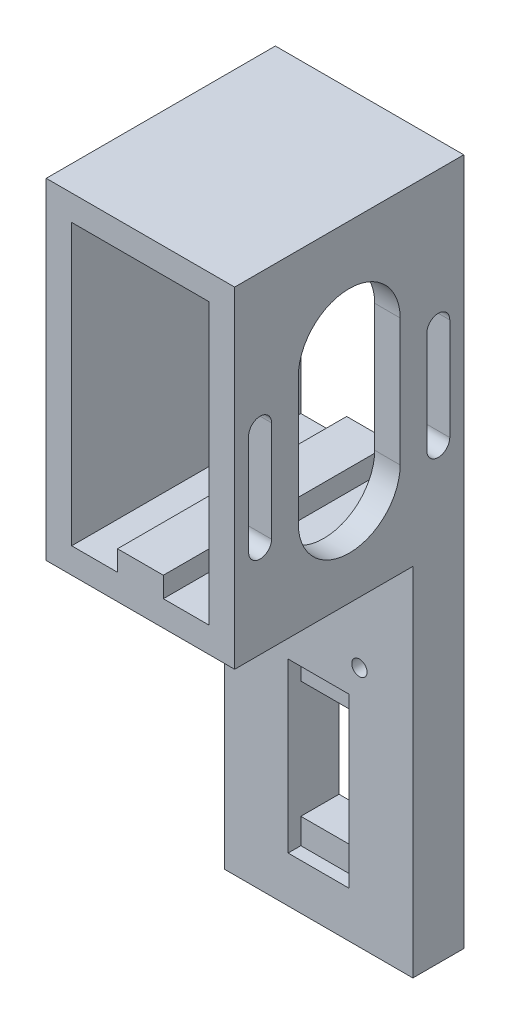
from build123d import *

# Parameters (mm, degrees)
BOSS_EXTRU_1_DEPTH      = 45
ENL_V_MAT_EXTRU_1_DEPTH = 5
ESQUISSE4_W             = 37
ESQUISSE4_H             = 45
BOSS_EXTRU_2_DEPTH      = 5
ESQUISSE5_W             = 37
ESQUISSE5_H             = 10
BOSS_EXTRU_3_DEPTH      = 70
ESQUISSE6_R             = 1
ENL_V_MAT_EXTRU_2_DEPTH = 10
CHANFREIN2_SIZE         = 1
ESQUISSE7_W             = 12
ESQUISSE7_H             = 23
ENL_V_MAT_EXTRU_3_DEPTH = 10
ESQUISSE8_W             = 12
ESQUISSE8_H             = 5
ENL_V_MAT_EXTRU_4_DEPTH = 2.5
ESQUISSE10_R            = 1.5
ENL_V_MAT_EXTRU_5_DEPTH = 10


with BuildPart() as part:
    # Esquisse1 → Boss.-Extru.1 (new body)
    with BuildSketch(Plane.XY):
        Polygon((-40.10574777, 31.587127795), (-35.10574777, 31.587127795), (-35.10574777, -23.412872205), (-26.10574777, -23.412872205), (-26.10574777, -19.412872205), (-17.10574777, -19.412872205), (-17.10574777, -23.412872205), (-8.10574777, -23.412872205), (-8.10574777, 31.587127795), (-3.10574777, 31.587127795), (-3.10574777, -28.412872205), (-40.10574777, -28.412872205), align=None)
    extrude(amount=BOSS_EXTRU_1_DEPTH)

    # Esquisse2 → Enlèv. mat.-Extru.1 (cut)
    with BuildSketch(Plane(origin=(-3.10574777, 0, 0), x_dir=(0, 0, -1), z_dir=(1, 0, 0))):
        with BuildLine():
            Line((-12.5, 15.087127795), (-12.5, -9.912872205))
            ThreePointArc((-12.5, -9.912872205), (-22.5, -19.912872205), (-32.5, -9.912872205))
            Line((-32.5, -9.912872205), (-32.5, 15.087127795))
            ThreePointArc((-32.5, 15.087127795), (-22.5, 25.087127795), (-12.5, 15.087127795))
        make_face()
        with BuildLine():
            Line((-37.75, 9.877519714), (-37.75, -9.912872205))
            ThreePointArc((-37.75, -9.912872205), (-40, -12.162872205), (-42.25, -9.912872205))
            Line((-42.25, -9.912872205), (-42.25, 9.877519714))
            ThreePointArc((-42.25, 9.877519714), (-40, 12.127519714), (-37.75, 9.877519714))
        make_face()
        with BuildLine():
            Line((-2.75, 9.877519714), (-2.75, -10.122480286))
            ThreePointArc((-2.75, -10.122480286), (-5, -12.372480286), (-7.25, -10.122480286))
            Line((-7.25, -10.122480286), (-7.25, 9.877519714))
            ThreePointArc((-7.25, 9.877519714), (-5, 12.127519714), (-2.75, 9.877519714))
        make_face()
    extrude(amount=-ENL_V_MAT_EXTRU_1_DEPTH, mode=Mode.SUBTRACT)

    # Esquisse4 → Boss.-Extru.2 (add)
    with BuildSketch(Plane(origin=(0, 31.587127795, 0), x_dir=(1, 0, 0), z_dir=(0, 1, 0))):
        with Locations((-21.60574777, -22.5)):
            Rectangle(ESQUISSE4_W, ESQUISSE4_H)
    extrude(amount=BOSS_EXTRU_2_DEPTH)

    # Esquisse5 → Boss.-Extru.3 (add)
    with BuildSketch(Plane.XZ.offset(28.412872205)):
        with Locations((-21.60574777, 5)):
            Rectangle(ESQUISSE5_W, ESQUISSE5_H)
    extrude(amount=BOSS_EXTRU_3_DEPTH)

    # Esquisse6 → Enlèv. mat.-Extru.2 (cut)
    with BuildSketch(Plane.ZY.offset(40.10574777)):
        with Locations((15, -18.412872205)):
            Circle(ESQUISSE6_R)
        with Locations((15, -8.912872205)):
            Circle(ESQUISSE6_R)
    extrude(amount=-ENL_V_MAT_EXTRU_2_DEPTH, mode=Mode.SUBTRACT)

    # Chanfrein2
    chanfrein2_edges = [part.edges().sort_by_distance(p)[0] for p in [
        (-35.10574777, -18.412872205, 14),
        (-35.10574777, -8.912872205, 14),
    ]]
    chamfer(chanfrein2_edges, length=CHANFREIN2_SIZE)

    # Esquisse7 → Enlèv. mat.-Extru.3 (cut)
    with BuildSketch(Plane.XY.offset(10)):
        with Locations((-21.60574777, -72.912872205)):
            Rectangle(ESQUISSE7_W, ESQUISSE7_H)
    extrude(amount=-ENL_V_MAT_EXTRU_3_DEPTH, mode=Mode.SUBTRACT)

    # Esquisse8 → Enlèv. mat.-Extru.4 (cut)
    with BuildSketch(Plane.XY.offset(10)):
        with Locations((-21.60574777, -58.912872205)):
            Rectangle(ESQUISSE8_W, ESQUISSE8_H)
        with Locations((-21.60574777, -86.912872205)):
            Rectangle(ESQUISSE8_W, ESQUISSE8_H)
    extrude(amount=-ENL_V_MAT_EXTRU_4_DEPTH, mode=Mode.SUBTRACT)

    # Esquisse10 → Enlèv. mat.-Extru.5 (cut)
    with BuildSketch(Plane.XY.offset(10)):
        with Locations((-29.60574777, -35.912872205)):
            Circle(ESQUISSE10_R)
        with Locations((-29.60574777, -50.912872205)):
            Circle(ESQUISSE10_R)
        with Locations((-13.60574777, -50.912872205)):
            Circle(ESQUISSE10_R)
        with Locations((-13.60574777, -35.912872205)):
            Circle(ESQUISSE10_R)
    extrude(amount=-ENL_V_MAT_EXTRU_5_DEPTH, mode=Mode.SUBTRACT)


solid = part.part
